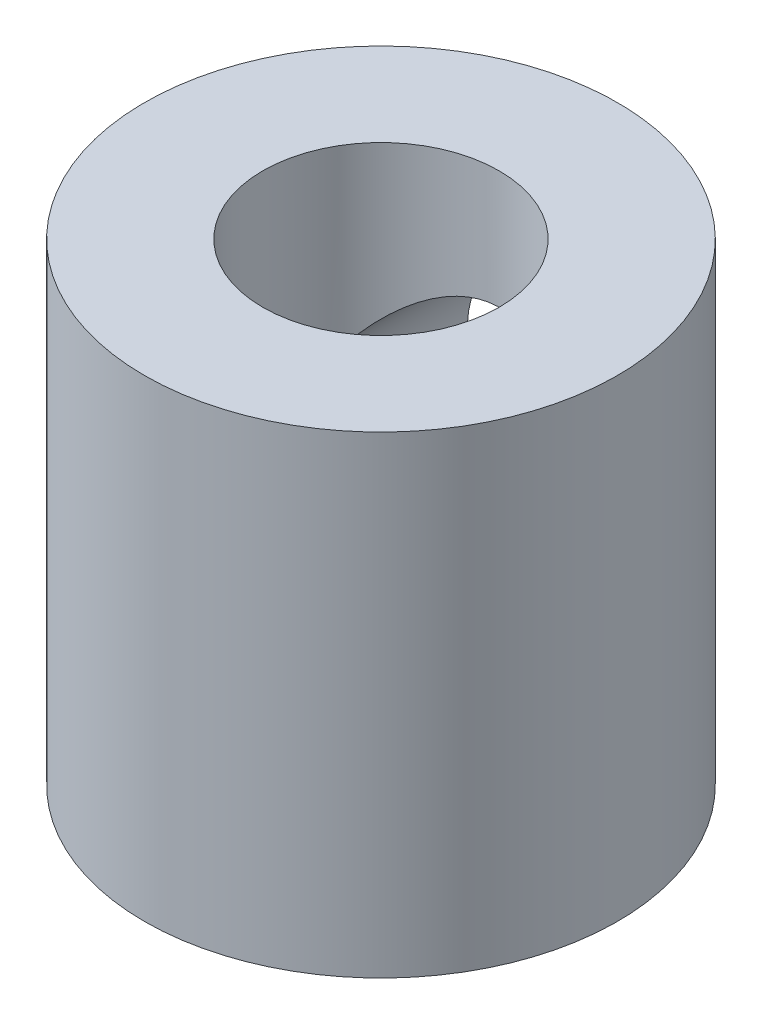
from build123d import *

# Parameters (mm, degrees)
SKETCH1_R           = 10
SKETCH1_R_2         = 5
BOSS_EXTRUDE1_DEPTH = 20
SKETCH2_R           = 5
CUT_EXTRUDE1_DEPTH  = 20


with BuildPart() as part:
    # Sketch1 → Boss-Extrude1 (new body)
    with BuildSketch(Plane(origin=(0, 0, 0), x_dir=(1, 0, 0), z_dir=(0, 1, 0))):
        Circle(SKETCH1_R)
        Circle(SKETCH1_R_2, mode=Mode.SUBTRACT)
    extrude(amount=BOSS_EXTRUDE1_DEPTH)

    # Sketch2 → Cut-Extrude1 (cut)
    with BuildSketch(Plane.XY):
        with Locations((0, 10)):
            Circle(SKETCH2_R)
    extrude(amount=-CUT_EXTRUDE1_DEPTH, mode=Mode.SUBTRACT)


solid = part.part
